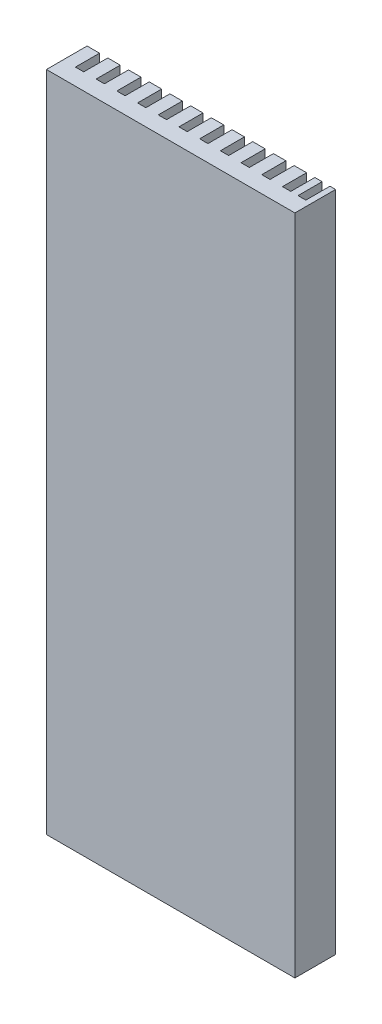
from build123d import *

# Parameters (mm, degrees)
EXTRUDE_1_DEPTH = 160


with BuildPart() as part:
    # Эскиз1 → Бобышка-Вытянуть1 (new body)
    with BuildSketch(Plane(origin=(0, 0, 0), x_dir=(1, 0, 0), z_dir=(0, 1, 0))):
        Polygon((-30, 0), (30, 0), (30, 9.81929979), (28.644603918, 9.81929979), (28.644603918, 4), (26.747359492, 4), (26.747359492, 9.81929979), (25, 9.81929979), (25, 4), (23, 4), (23, 9.81929979), (20, 9.81929979), (20, 4), (18, 4), (18, 9.81929979), (15, 9.81929979), (15, 4), (13, 4), (13, 9.81929979), (10, 9.81929979), (10, 4), (8, 4), (8, 9.81929979), (5, 9.81929979), (5, 4), (3, 4), (3, 9.81929979), (0, 9.81929979), (0, 4), (-2, 4), (-2, 9.81929979), (-5, 9.81929979), (-5, 4), (-7, 4), (-7, 9.81929979), (-10, 9.81929979), (-10, 4), (-12, 4), (-12, 9.81929979), (-15, 9.81929979), (-15, 4), (-17, 4), (-17, 9.81929979), (-20, 9.81929979), (-20, 4), (-22, 4), (-22, 9.81929979), (-25, 9.81929979), (-25, 4), (-27, 4), (-27, 9.81929979), (-30, 9.81929979), align=None)
    extrude(amount=EXTRUDE_1_DEPTH)


solid = part.part
